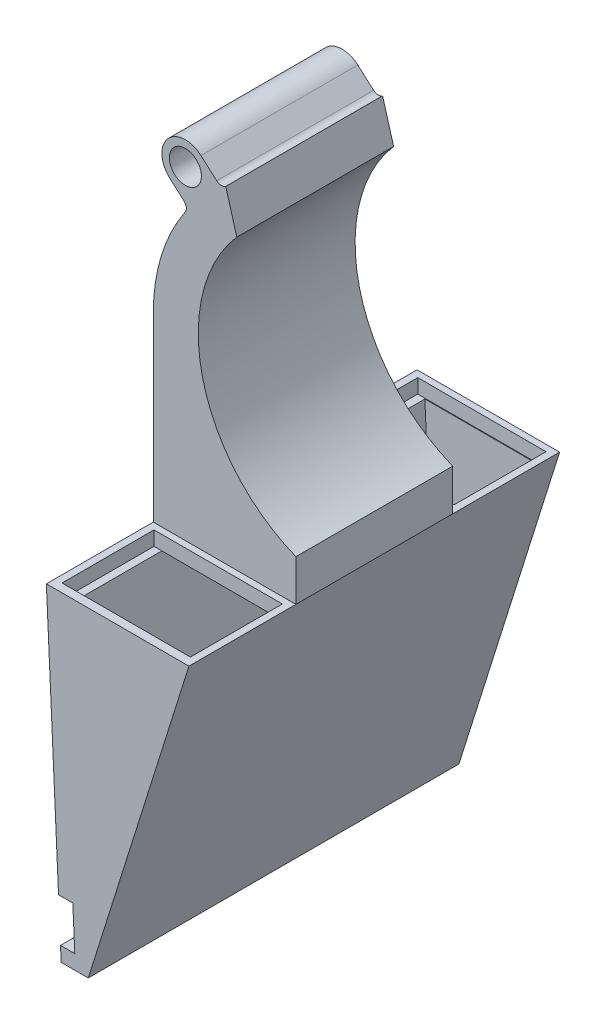
from build123d import *

# Parameters (mm, degrees)
BOSS_EXTRUDE1_DEPTH = 52
BOSS_EXTRUDE2_DEPTH = 1
BOSS_EXTRUDE3_START = -52
BOSS_EXTRUDE3_DEPTH = 1
SKETCH4_W           = 18.000000053
SKETCH4_H           = 12.9
SKETCH4_W_2         = 18
CUT_EXTRUDE1_DEPTH  = 2
SKETCH5_R           = 3.3
SKETCH5_R_2         = 2.25
BOSS_EXTRUDE4_DEPTH = 22


with BuildPart() as part:
    # Sketch2 → Boss-Extrude1 (new body)
    with BuildSketch(Plane.XY):
        Polygon((-21.624010924, -70.352088598), (-7.5, -25.4), (-27.5, -25.4), (-25.794353309, -62.332940574), (-23.792221644, -62.332940574), (-25.405503813, -27.4), (-10.224802214, -27.4), (-23.085991045, -68.332940574), (-23.515128079, -68.332940574), (-25.517259745, -68.332940574), (-25.424010924, -70.352088598), align=None)
    extrude(amount=-BOSS_EXTRUDE1_DEPTH)

    # Sketch2_3 → Boss-Extrude2 (add)
    with BuildSketch(Plane.XY):
        Polygon((-23.515128079, -68.332940574), (-23.085991045, -68.332940574), (-10.224802214, -27.4), (-25.405503813, -27.4), align=None)
    extrude(amount=-BOSS_EXTRUDE2_DEPTH)

    # Sketch2_4 → Boss-Extrude3 (add)
    with BuildSketch(Plane.XY.offset(BOSS_EXTRUDE3_START)):
        Polygon((-23.515128079, -68.332940574), (-23.085991045, -68.332940574), (-10.224802214, -27.4), (-25.405503813, -27.4), align=None)
    extrude(amount=BOSS_EXTRUDE3_DEPTH)

    # Sketch4 → Cut-Extrude1 (cut)
    with BuildSketch(Plane.XZ.offset(25.4)):
        with Locations((-17.500000027, -7.65)):
            Rectangle(SKETCH4_W, SKETCH4_H)
        with Locations((-17.5, -44.65)):
            Rectangle(SKETCH4_W_2, SKETCH4_H)
    extrude(amount=CUT_EXTRUDE1_DEPTH, mode=Mode.SUBTRACT)

    # Sketch5 → Boss-Extrude4 (add)
    with BuildSketch(Plane(origin=(0, 0, -15), x_dir=(-1, 0, 0), z_dir=(0, 0, -1))):
        with BuildLine():
            Line((7.5, -22.955849111), (7.5, -25.4))
            Line((7.5, -25.4), (27.5, -25.4))
            Line((27.5, -25.4), (27.5, 0.016796875))
            ThreePointArc((27.5, 0.016796875), (26.360398691, 7.577422908), (23.04284729, 14.466226133))
            ThreePointArc((23.04284729, 14.466226133), (22.876796583, 15.153555184), (23.20688118, 15.778885673))
            Line((23.20688118, 15.778885673), (25.185252728, 17.527214018))
            ThreePointArc((25.185252728, 17.527214018), (20.527214018, 17.814747272), (20.814747272, 22.472785982))
            Line((20.814747272, 22.472785982), (18.598905377, 20.514600122))
            ThreePointArc((18.598905377, 20.514600122), (17.974550182, 20.264645495), (17.333078903, 20.466663618))
            Line((17.333078903, 20.466663618), (15.787974775, 15.080867994))
            ThreePointArc((15.787974775, 15.080867994), (20.592977306, -4.399589042), (7.5, -19.60321364))
            Line((7.5, -19.60321364), (7.5, -22.955849111))
        make_face()
        with Locations((23, 20)):
            Circle(SKETCH5_R)
        with Locations((23, 20)):
            Circle(SKETCH5_R_2, mode=Mode.SUBTRACT)
    extrude(amount=BOSS_EXTRUDE4_DEPTH)


solid = part.part
